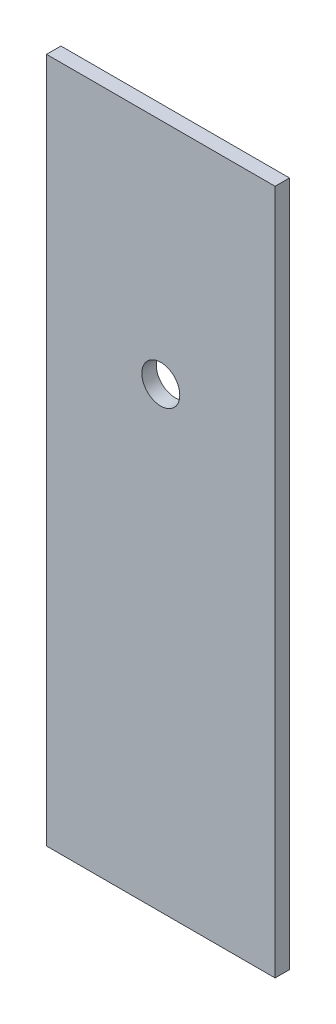
from build123d import *

# Parameters (mm, degrees)
SKETCH1_W           = 25.4
SKETCH1_H           = 76.2
BOSS_EXTRUDE1_DEPTH = 1.6002
SKETCH2_R           = 2.1082
CUT_EXTRUDE1_DEPTH  = 1.6002


with BuildPart() as part:
    # Sketch1 → Boss-Extrude1 (new body)
    with BuildSketch(Plane.XY):
        Rectangle(SKETCH1_W, SKETCH1_H)
    extrude(amount=BOSS_EXTRUDE1_DEPTH)

    # Sketch2 → Cut-Extrude1 (cut)
    with BuildSketch(Plane.XY.offset(1.6002)):
        with Locations((0, 12.7)):
            Circle(SKETCH2_R)
    extrude(amount=-CUT_EXTRUDE1_DEPTH, mode=Mode.SUBTRACT)


solid = part.part
